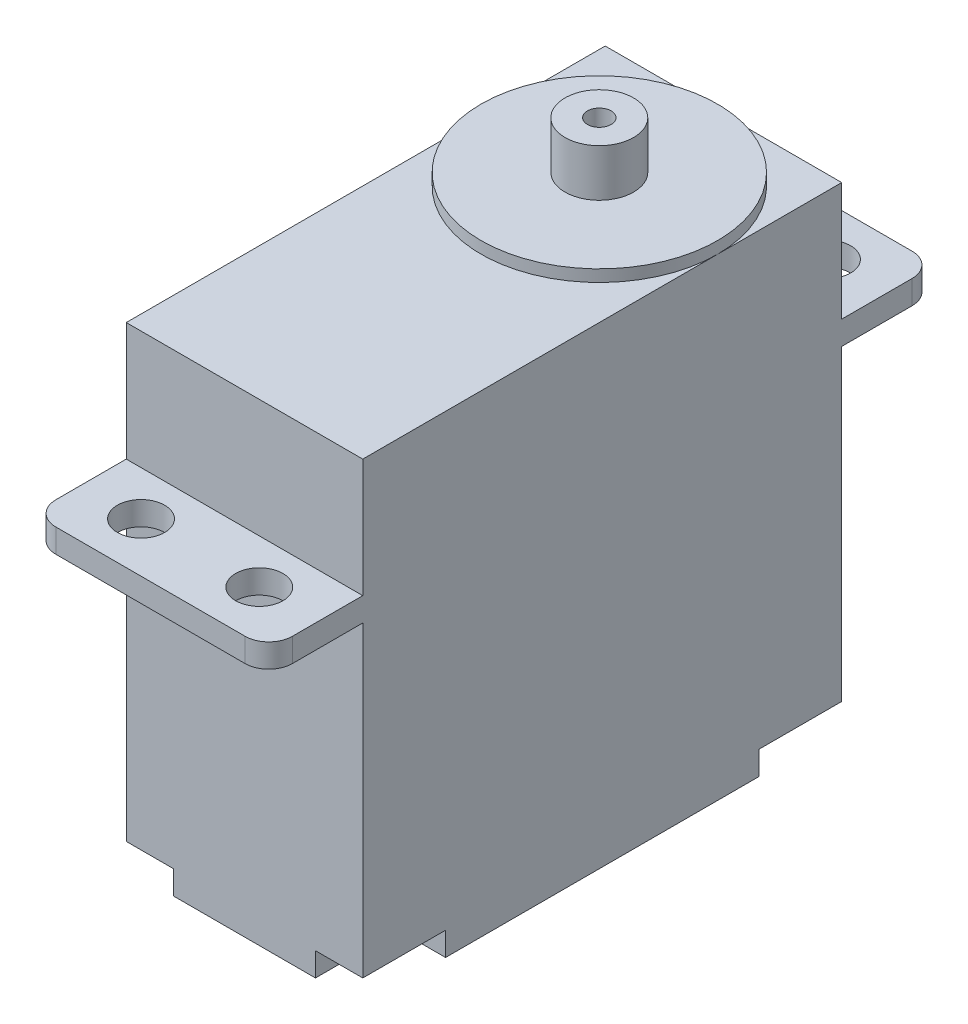
from build123d import *

# Parameters (mm, degrees)
SKETCH2_W           = 20
SKETCH2_H           = 40.5
BOSS_EXTRUDE1_DEPTH = 28
SKETCH3_W           = 20
SKETCH3_H           = 56.4
BOSS_EXTRUDE2_DEPTH = 2
SKETCH4_W           = 20
SKETCH4_H           = 40.5
BOSS_EXTRUDE3_DEPTH = 10
SKETCH5_R           = 10
BOSS_EXTRUDE4_DEPTH = 1
SKETCH6_R           = 2.9
SKETCH6_R_2         = 1
BOSS_EXTRUDE5_DEPTH = 4
SKETCH7_R           = 2
CUT_EXTRUDE1_DEPTH  = 2
FILLET1_R           = 2
SKETCH8_W           = 4
SKETCH8_H           = 7
CUT_EXTRUDE2_DEPTH  = 2
SKETCH9_W           = 8
SKETCH9_H           = 3
BOSS_EXTRUDE6_DEPTH = 5


with BuildPart() as part:
    # Sketch2 → Boss-Extrude1 (new body)
    with BuildSketch(Plane(origin=(0, 77, 0), x_dir=(1, 0, 0), z_dir=(0, 1, 0))):
        with Locations((-39.282617367, 276.14521975)):
            Rectangle(SKETCH2_W, SKETCH2_H)
    extrude(amount=BOSS_EXTRUDE1_DEPTH)

    # Sketch3 → Boss-Extrude2 (add)
    with BuildSketch(Plane(origin=(0, 105, 0), x_dir=(1, 0, 0), z_dir=(0, 1, 0))):
        with Locations((-39.282617367, 276.14521975)):
            Rectangle(SKETCH3_W, SKETCH3_H)
    extrude(amount=BOSS_EXTRUDE2_DEPTH)

    # Sketch4 → Boss-Extrude3 (add)
    with BuildSketch(Plane(origin=(0, 107, 0), x_dir=(1, 0, 0), z_dir=(0, 1, 0))):
        with Locations((-39.282617367, 276.14521975)):
            Rectangle(SKETCH4_W, SKETCH4_H)
    extrude(amount=BOSS_EXTRUDE3_DEPTH)

    # Sketch5 → Boss-Extrude4 (add)
    with BuildSketch(Plane(origin=(0, 117, 0), x_dir=(1, 0, 0), z_dir=(0, 1, 0))):
        with Locations((-39.282617367, 285.89521975)):
            Circle(SKETCH5_R)
    extrude(amount=BOSS_EXTRUDE4_DEPTH)

    # Sketch6 → Boss-Extrude5 (add)
    with BuildSketch(Plane(origin=(0, 118, 0), x_dir=(1, 0, 0), z_dir=(0, 1, 0))):
        with Locations((-39.282617367, 285.89521975)):
            Circle(SKETCH6_R)
        with Locations((-39.282617367, 285.89521975)):
            Circle(SKETCH6_R_2, mode=Mode.SUBTRACT)
    extrude(amount=BOSS_EXTRUDE5_DEPTH)

    # Sketch7 → Cut-Extrude1 (cut)
    with BuildSketch(Plane(origin=(0, 107, 0), x_dir=(1, 0, 0), z_dir=(0, 1, 0))):
        with Locations((-44.282617367, 252.14521975)):
            Circle(SKETCH7_R)
        with Locations((-34.282617367, 252.14521975)):
            Circle(SKETCH7_R)
        with Locations((-34.282617367, 300.14521975)):
            Circle(SKETCH7_R)
        with Locations((-44.282617367, 300.14521975)):
            Circle(SKETCH7_R)
    extrude(amount=-CUT_EXTRUDE1_DEPTH, mode=Mode.SUBTRACT)

    # Fillet1
    fillet1_edges = [part.edges().sort_by_distance(p)[0] for p in [
        (-49.282617367, 106, -304.34521975),
        (-49.282617367, 106, -247.94521975),
        (-29.282617367, 106, -247.94521975),
        (-29.282617367, 106, -304.34521975),
    ]]
    fillet(fillet1_edges, radius=FILLET1_R)

    # Sketch8 → Cut-Extrude2 (cut)
    with BuildSketch(Plane.XZ.offset(-77)):
        with Locations((-31.282617367, -259.39521975)):
            Rectangle(SKETCH8_W, SKETCH8_H)
        with Locations((-31.282617367, -292.89521975)):
            Rectangle(SKETCH8_W, SKETCH8_H)
        with Locations((-47.282617367, -292.89521975)):
            Rectangle(SKETCH8_W, SKETCH8_H)
        with Locations((-47.282617367, -259.39521975)):
            Rectangle(SKETCH8_W, SKETCH8_H)
    extrude(amount=-CUT_EXTRUDE2_DEPTH, mode=Mode.SUBTRACT)

    # Sketch9 → Boss-Extrude6 (add)
    with BuildSketch(Plane(origin=(0, 0, -296.39521975), x_dir=(-1, 0, 0), z_dir=(0, 0, -1))):
        with Locations((39.282617367, 78.5)):
            Rectangle(SKETCH9_W, SKETCH9_H)
    extrude(amount=BOSS_EXTRUDE6_DEPTH)


solid = part.part
